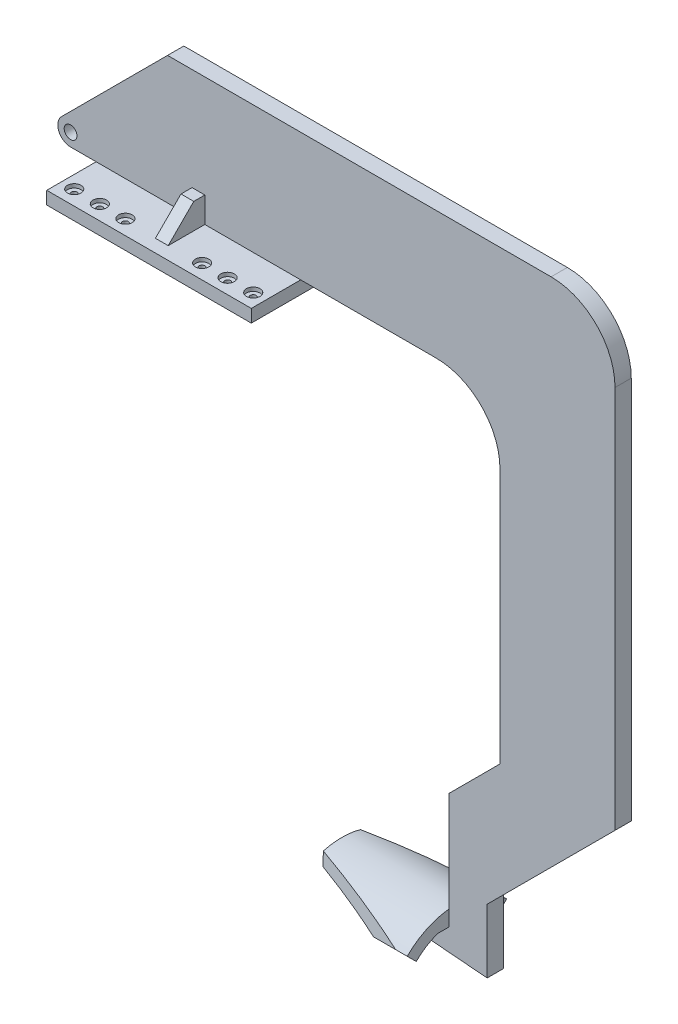
from build123d import *

# Parameters (mm, degrees)
SKETCH1_R                                        = 5
BOSS_EXTRUDE1_DEPTH                              = 30
SKETCH2_W                                        = 160
SKETCH2_H                                        = 30
BOSS_EXTRUDE2_DEPTH                              = 10
RIB1_REACH                                       = 529.146
SKETCH5_WALL_W                                   = 1084.577110596
SKETCH5_WALL_H                                   = 10
RIB17_REACH                                      = 529.146
SKETCH7_WALL_W                                   = 1084.577110596
SKETCH7_WALL_H                                   = 10
CBORE_FOR_M4_HEX_HEAD_MACHINE_SCREW2_D           = 4.5
CBORE_FOR_M4_HEX_HEAD_MACHINE_SCREW2_CBORE_D     = 10.59
CBORE_FOR_M4_HEX_HEAD_MACHINE_SCREW2_CBORE_DEPTH = 3
MIRROR2_COPY_1_D                                 = 4.5
MIRROR2_COPY_1_CBORE_D                           = 10.59
MIRROR2_COPY_1_CBORE_DEPTH                       = 3
BOSS_EXTRUDE5_DEPTH                              = 90
CUT_EXTRUDE4_DEPTH                               = 100
CUT_EXTRUDE4_DEPTH_BACK                          = 100
CUT_EXTRUDE5_DEPTH                               = 8.65
CUT_EXTRUDE6_DEPTH                               = 8.65


with BuildPart() as part:
    # Sketch1 → Boss-Extrude1 (new body)
    with BuildSketch(Plane.XY):
        with BuildLine():
            Line((-7.071067812, 7.071067812), (75.857864376, 90))
            Line((75.857864376, 90), (375.857864376, 90))
            ThreePointArc((375.857864376, 90), (411.213203436, 75.355339059), (425.857864376, 40))
            Line((425.857864376, 40), (425.857864376, -260))
            Line((425.857864376, -260), (325.857864376, -360))
            Line((325.857864376, -360), (325.857864376, -410))
            Line((325.857864376, -410), (205.857864376, -400))
            Line((205.857864376, -400), (205.857864376, -380))
            Line((205.857864376, -380), (295.857864376, -380))
            Line((295.857864376, -380), (295.857864376, -300))
            Line((295.857864376, -300), (335.857864376, -260))
            Line((335.857864376, -260), (335.857864376, -60))
            ThreePointArc((335.857864376, -60), (321.213203436, -24.644660941), (285.857864376, -10))
            Line((285.857864376, -10), (0, -10))
            ThreePointArc((0, -10), (-9.238795325, -3.826834324), (-7.071067812, 7.071067812))
        make_face()
        Circle(SKETCH1_R, mode=Mode.SUBTRACT)
    extrude(amount=BOSS_EXTRUDE1_DEPTH)

    # Sketch2 → Boss-Extrude2 (add)
    with BuildSketch(Plane.XZ.offset(10)):
        with Locations((100, 45)):
            Rectangle(SKETCH2_W, SKETCH2_H)
        with Locations((100, 15)):
            Rectangle(SKETCH2_W, SKETCH2_H)
        with Locations((100, -15)):
            Rectangle(SKETCH2_W, SKETCH2_H)
    extrude(amount=BOSS_EXTRUDE2_DEPTH)

    # Sketch5 wall → Rib1 (add, up to next)
    with BuildSketch(Plane(origin=(100, 0, 40), x_dir=(0, -0.707106781187, 0.707106781187), z_dir=(0, 0.707106781187, 0.707106781187)), mode=Mode.PRIVATE) as rib1_sk1:
        Rectangle(SKETCH5_WALL_W, SKETCH5_WALL_H)
    rib1_tool1 = extrude(rib1_sk1.sketch, amount=-RIB1_REACH, mode=Mode.PRIVATE) - part.part
    add(rib1_tool1.solids().sort_by_distance((100, 0, 40))[0])

    # Sketch7 wall → Rib17 (add, up to next)
    with BuildSketch(Plane(origin=(100, 0, -10), x_dir=(0, -0.707106781187, -0.707106781187), z_dir=(0, -0.707106781187, 0.707106781187)), mode=Mode.PRIVATE) as rib17_sk1:
        Rectangle(SKETCH7_WALL_W, SKETCH7_WALL_H)
    rib17_tool1 = extrude(rib17_sk1.sketch, amount=RIB17_REACH, mode=Mode.PRIVATE) - part.part
    add(rib17_tool1.solids().sort_by_distance((100, 0, -10))[0])

    # CBORE for M4 Hex Head Machine Screw2 (through all)
    with Locations(Plane(origin=(0, -10, 0), x_dir=(1, 0, 0), z_dir=(0, 1, 0))):
        with Locations((130, -48.5), (150, -48.5), (170, -48.5)):
            cbore_for_m4_hex_head_machine_screw2 = CounterBoreHole(CBORE_FOR_M4_HEX_HEAD_MACHINE_SCREW2_D / 2, CBORE_FOR_M4_HEX_HEAD_MACHINE_SCREW2_CBORE_D / 2, CBORE_FOR_M4_HEX_HEAD_MACHINE_SCREW2_CBORE_DEPTH)

    # Mirror1: CBORE for M4 Hex Head Machine Screw2 across plane
    add(cbore_for_m4_hex_head_machine_screw2.mirror(Plane(origin=(100, 0, 0), x_dir=(0, 0, 1), z_dir=(1, 0, 0))), mode=Mode.SUBTRACT)

    # Mirror2: CBORE for M4 Hex Head Machine Screw2 across plane
    add(cbore_for_m4_hex_head_machine_screw2.mirror(Plane.XY.offset(16)), mode=Mode.SUBTRACT)

    # Mirror2 copy 1 (through all)
    with Locations(Plane(origin=(200, -10, 32), x_dir=(-1, 0, 0), z_dir=(0, 1, 0))):
        with Locations((130, -48.5), (150, -48.5), (170, -48.5)):
            CounterBoreHole(MIRROR2_COPY_1_D / 2, MIRROR2_COPY_1_CBORE_D / 2, MIRROR2_COPY_1_CBORE_DEPTH)

    # Sketch19 → Boss-Extrude5 (add)
    with BuildSketch(Plane.ZY.offset(-295.857864376)):
        with BuildLine():
            Line((-23.890872965, -394.024153256), (-16.819805153, -401.095221068))
            ThreePointArc((-16.819805153, -401.095221068), (15, -387.915026221), (46.819805153, -401.095221068))
            Line((46.819805153, -401.095221068), (53.890872965, -394.024153256))
            ThreePointArc((53.890872965, -394.024153256), (15, -377.915026221), (-23.890872965, -394.024153256))
        make_face()
    extrude(amount=BOSS_EXTRUDE5_DEPTH)

    # Sketch20 → Cut-Extrude4 (cut, two sides)
    with BuildSketch(Plane(origin=(-31.683738866, -380.204866396, 0), x_dir=(0.9965457582448797, -0.08304547985374006, 0), z_dir=(-0.08304547985374006, -0.9965457582448797, 0))) as cut_extrude4_sk:
        Polygon((228.178842993, -32.182148517), (344.185851358, -32.182148517), (238.364973487, 0), (228.178842993, 3.097796682), align=None)
        Polygon((238.364973487, 30), (346.499317462, 62.242718318), (228.178842993, 62.242718318), (228.178842993, 26.962773119), align=None)
    extrude(amount=CUT_EXTRUDE4_DEPTH, mode=Mode.SUBTRACT)
    extrude(cut_extrude4_sk.sketch, amount=-CUT_EXTRUDE4_DEPTH_BACK, mode=Mode.SUBTRACT)

    # Sketch21 → Cut-Extrude5 (cut)
    with BuildSketch(Plane.XY.offset(30)):
        with BuildLine():
            Line((206.65047943, -390.48861935), (205.857864376, -390.48861935))
            Line((205.857864376, -390.48861935), (205.857864376, -400))
            Line((205.857864376, -400), (325.857864376, -410))
            Line((325.857864376, -410), (325.857864376, -360))
            Line((325.857864376, -360), (425.857864376, -260))
            Line((425.857864376, -260), (425.857864376, 40))
            ThreePointArc((425.857864376, 40), (411.213203436, 75.355339059), (375.857864376, 90))
            Line((375.857864376, 90), (75.857864376, 90))
            Line((75.857864376, 90), (-7.071067812, 7.071067812))
            ThreePointArc((-7.071067812, 7.071067812), (-9.238795325, -3.826834324), (0, -10))
            Line((0, -10), (20, -10))
            Line((20, -10), (95, -10))
            Line((95, -10), (95, 10))
            Line((95, 10), (105, 10))
            Line((105, 10), (105, -10))
            Line((105, -10), (180, -10))
            Line((180, -10), (285.857864376, -10))
            ThreePointArc((285.857864376, -10), (321.213203436, -24.644660941), (335.857864376, -60))
            Line((335.857864376, -60), (335.857864376, -260))
            Line((335.857864376, -260), (295.857864376, -300))
            Line((295.857864376, -300), (295.857864376, -380))
            Line((295.857864376, -380), (295.857864376, -390.48861935))
            Line((295.857864376, -390.48861935), (206.65047943, -390.48861935))
        make_face()
    extrude(amount=-CUT_EXTRUDE5_DEPTH, mode=Mode.SUBTRACT)

    # Sketch22 → Cut-Extrude6 (cut)
    with BuildSketch(Plane(origin=(0, 0, 0), x_dir=(-1, 0, 0), z_dir=(0, 0, -1))):
        with BuildLine():
            Line((-206.65047943, -390.48861935), (-205.857864376, -390.48861935))
            Line((-205.857864376, -390.48861935), (-205.857864376, -400))
            Line((-205.857864376, -400), (-325.857864376, -410))
            Line((-325.857864376, -410), (-325.857864376, -360))
            Line((-325.857864376, -360), (-425.857864376, -260))
            Line((-425.857864376, -260), (-425.857864376, 40))
            ThreePointArc((-425.857864376, 40), (-411.213203436, 75.355339059), (-375.857864376, 90))
            Line((-375.857864376, 90), (-75.857864376, 90))
            Line((-75.857864376, 90), (7.071067812, 7.071067812))
            ThreePointArc((7.071067812, 7.071067812), (9.238795325, -3.826834324), (0, -10))
            Line((0, -10), (-20, -10))
            Line((-20, -10), (-95, -10))
            Line((-95, -10), (-95, 10))
            Line((-95, 10), (-105, 10))
            Line((-105, 10), (-105, -10))
            Line((-105, -10), (-180, -10))
            Line((-180, -10), (-285.857864376, -10))
            ThreePointArc((-285.857864376, -10), (-321.213203436, -24.644660941), (-335.857864376, -60))
            Line((-335.857864376, -60), (-335.857864376, -260))
            Line((-335.857864376, -260), (-295.857864376, -300))
            Line((-295.857864376, -300), (-295.857864376, -380))
            Line((-295.857864376, -380), (-295.857864376, -390.48861935))
            Line((-295.857864376, -390.48861935), (-206.65047943, -390.48861935))
        make_face()
    extrude(amount=-CUT_EXTRUDE6_DEPTH, mode=Mode.SUBTRACT)


solid = part.part
